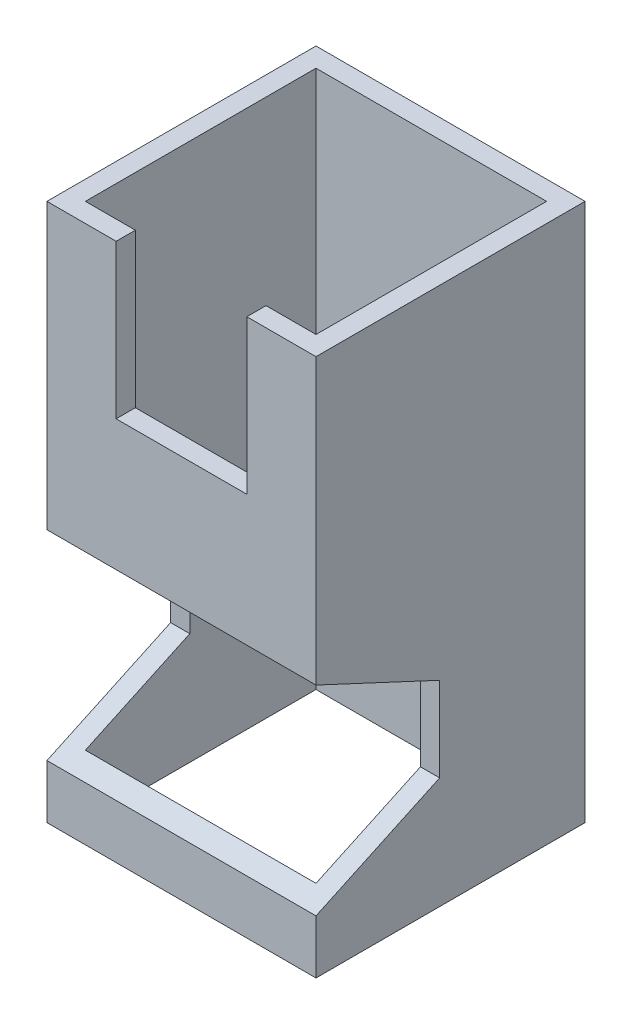
from build123d import *

# Parameters (mm, degrees)
SKETCH1_W           = 35
SKETCH1_H           = 35
SKETCH1_W_2         = 30
SKETCH1_H_2         = 30
BOSS_EXTRUDE1_DEPTH = 70
SKETCH2_W           = 17
SKETCH2_H           = 20
CUT_EXTRUDE1_DEPTH  = 2.5
CUT_EXTRUDE2_DEPTH  = 36


with BuildPart() as part:
    # Sketch1 → Boss-Extrude1 (new body)
    with BuildSketch(Plane(origin=(0, 0, 0), x_dir=(1, 0, 0), z_dir=(0, 1, 0))):
        with Locations((15, 15)):
            Rectangle(SKETCH1_W, SKETCH1_H)
        with Locations((15, 15)):
            Rectangle(SKETCH1_W_2, SKETCH1_H_2, mode=Mode.SUBTRACT)
    extrude(amount=BOSS_EXTRUDE1_DEPTH)

    # Sketch2 → Cut-Extrude1 (cut)
    with BuildSketch(Plane.XY.offset(2.5)):
        with Locations((15, 60)):
            Rectangle(SKETCH2_W, SKETCH2_H)
    extrude(amount=-CUT_EXTRUDE1_DEPTH, mode=Mode.SUBTRACT)

    # Sketch3 → Cut-Extrude2 (cut, through all)
    with BuildSketch(Plane.ZY.offset(2.5)):
        Polygon((2.5, 33), (-13.583801904, 25.5), (-13.583801904, 14.5), (2.5, 7), align=None)
    extrude(amount=-CUT_EXTRUDE2_DEPTH, mode=Mode.SUBTRACT)


solid = part.part
